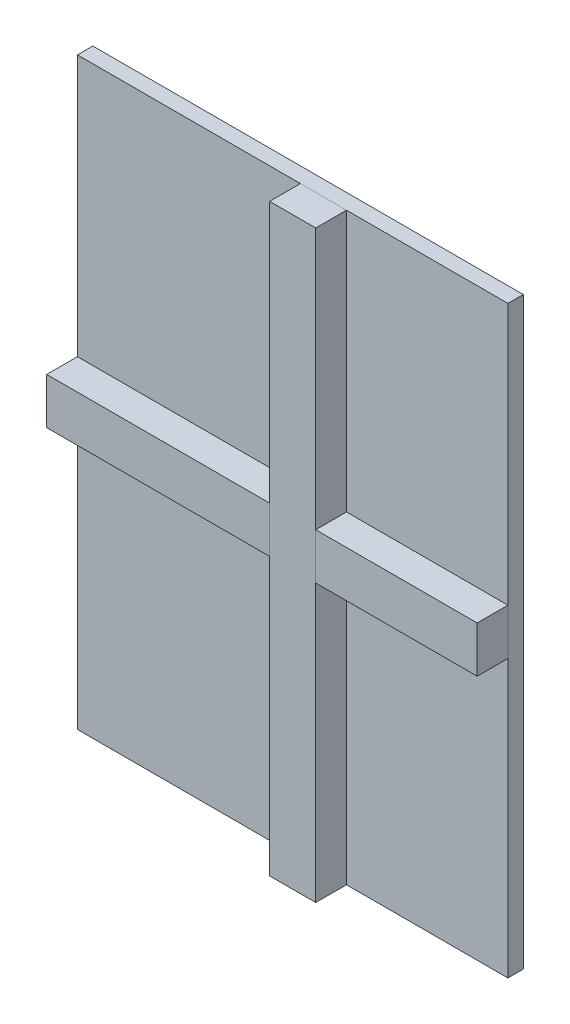
from build123d import *

# Parameters (mm, degrees)
SKETCH1_W           = 1400
SKETCH1_H           = 1900
BOSS_EXTRUDE1_DEPTH = 50
SKETCH3_W           = 100
SKETCH3_H           = 150
BOSS_EXTRUDE3_DEPTH = 1400
SKETCH4_W           = 150
SKETCH4_H           = 100
BOSS_EXTRUDE4_DEPTH = 1900


with BuildPart() as part:
    # Sketch1 → Boss-Extrude1 (new body)
    with BuildSketch(Plane.XY):
        with Locations((-709.010111523, 1763.08)):
            Rectangle(SKETCH1_W, SKETCH1_H)
    extrude(amount=BOSS_EXTRUDE1_DEPTH)


with BuildPart() as body_2:
    # Sketch3 → Boss-Extrude3 (new body)
    with BuildSketch(Plane(origin=(-9.010111523, 0, 0), x_dir=(0, 0, -1), z_dir=(1, 0, 0))):
        with Locations((-100, 1788.08)):
            Rectangle(SKETCH3_W, SKETCH3_H)
    extrude(amount=-BOSS_EXTRUDE3_DEPTH)


with BuildPart() as body_3:
    # Sketch4 → Boss-Extrude4 (new body)
    with BuildSketch(Plane.XZ.offset(-813.08)):
        with Locations((-609.010111523, 100)):
            Rectangle(SKETCH4_W, SKETCH4_H)
    extrude(amount=-BOSS_EXTRUDE4_DEPTH)


solid = Compound([part.part, body_2.part, body_3.part])
